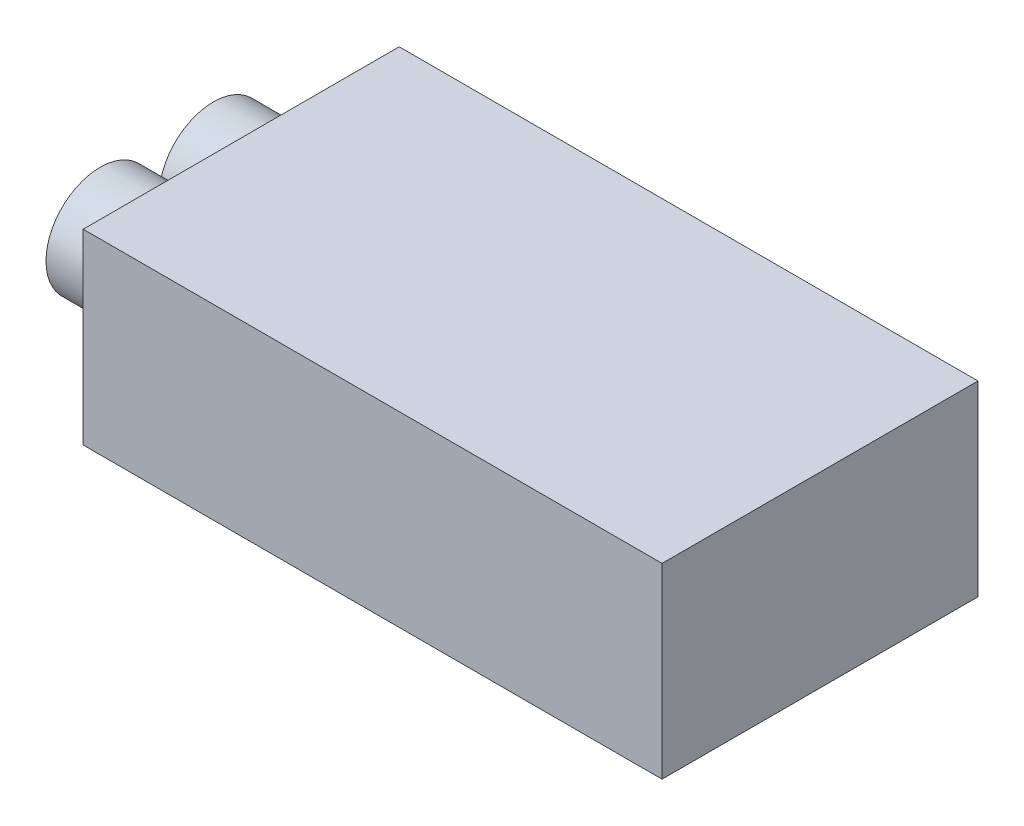
from build123d import *

# Parameters (mm, degrees)
SKETCH1_W           = 48
SKETCH1_H           = 26.201150123
BOSS_EXTRUDE1_DEPTH = 15.5
BOSS_EXTRUDE2_DEPTH = 7


with BuildPart() as part:
    # Sketch1 → Boss-Extrude1 (new body)
    with BuildSketch(Plane(origin=(0, 0, 0), x_dir=(1, 0, 0), z_dir=(0, 1, 0))):
        with Locations((24, 13.100575062)):
            Rectangle(SKETCH1_W, SKETCH1_H)
    extrude(amount=BOSS_EXTRUDE1_DEPTH)


with BuildPart() as body_2:
    # Sketch2 → Boss-Extrude2 (new body)
    with BuildSketch(Plane.ZY):
        with BuildLine():
            ThreePointArc((-13.292024285, 7.75), (-17.789975763, 12.247951478), (-22.287927242, 7.75))
            Line((-22.287927242, 7.75), (-13.292024285, 7.75))
        make_face()
        with BuildLine():
            Line((-13.292024285, 7.75), (-22.287927242, 7.75))
            ThreePointArc((-22.287927242, 7.75), (-17.789975763, 3.252048522), (-13.292024285, 7.75))
        make_face()
        with BuildLine():
            ThreePointArc((-3.913222881, 7.75), (-8.411174359, 12.247951478), (-12.909125838, 7.75))
            Line((-12.909125838, 7.75), (-3.913222881, 7.75))
        make_face()
        with BuildLine():
            Line((-3.913222881, 7.75), (-12.909125838, 7.75))
            ThreePointArc((-12.909125838, 7.75), (-8.411174359, 3.252048522), (-3.913222881, 7.75))
        make_face()
    extrude(amount=BOSS_EXTRUDE2_DEPTH)


solid = Compound([part.part, body_2.part])
